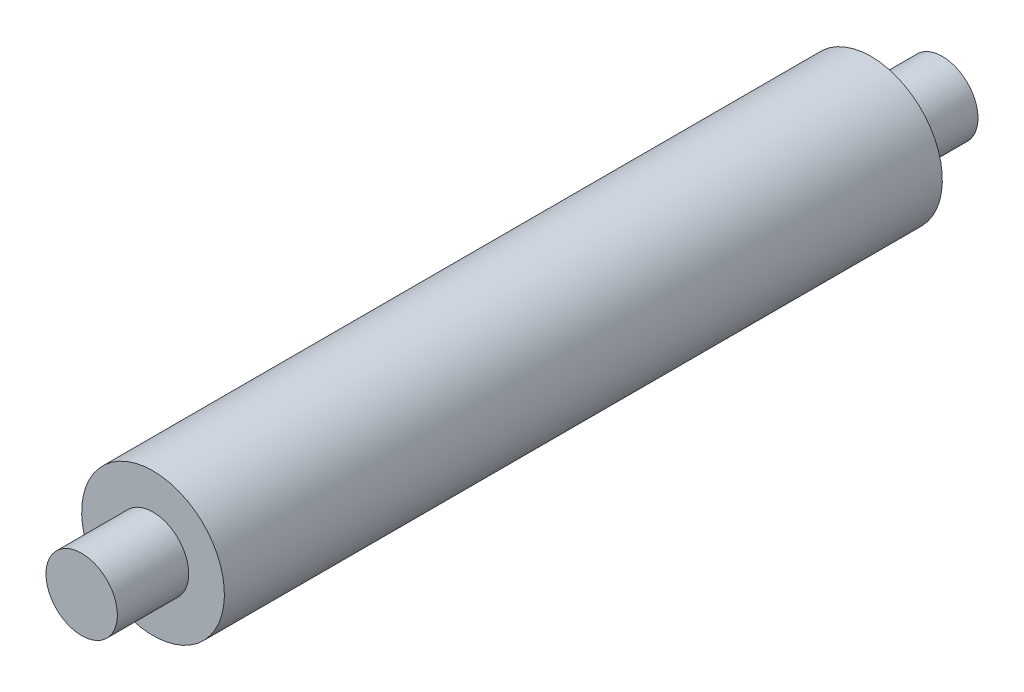
from build123d import *

# Parameters (mm, degrees)
SKETCH1_W   = 12.7
SKETCH1_H   = 6.35
SKETCH1_W_2 = 127.762
SKETCH1_H_2 = 12.7


with BuildPart() as part:
    # Sketch1 → Revolve1 (revolve)
    with BuildSketch(Plane(origin=(0, 0, 0), x_dir=(0, 0, -1), z_dir=(1, 0, 0))):
        with Locations((-134.112, 3.175)):
            Rectangle(SKETCH1_W, SKETCH1_H)
        with Locations((-63.881, 6.35)):
            Rectangle(SKETCH1_W_2, SKETCH1_H_2)
        with Locations((6.35, 3.175)):
            Rectangle(SKETCH1_W, SKETCH1_H)
    revolve(axis=Axis((0, 0, 0), (0, 0, 1)))


solid = part.part
